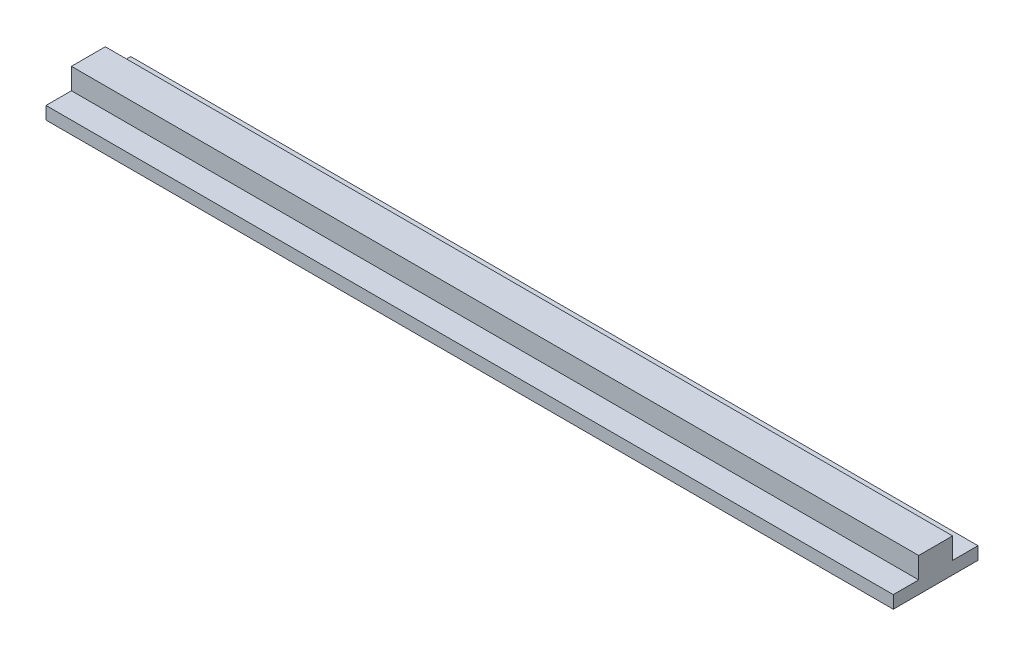
from build123d import *

# Parameters (mm, degrees)
RESSALTO_EXTRUS_O1_DEPTH = 1000
ESBO_O2_R                = 20
RESSALTO_EXTRUS_O2_DEPTH = 30


with BuildPart() as part:
    # Esboço1 → Ressalto-extrusão1 (new body, symmetric)
    with BuildSketch(Plane(origin=(0, 0, 0), x_dir=(0, 0, -1), z_dir=(1, 0, 0))):
        Polygon((-40, 80), (40, 80), (40, 30), (100, 30), (100, 0), (-100, 0), (-100, 30), (-40, 30), align=None)
    extrude(amount=RESSALTO_EXTRUS_O1_DEPTH, both=True)

    # Esboço2 → Ressalto-extrusão2 (add)
    with BuildSketch(Plane(origin=(0, 0, 0), x_dir=(-1, 0, 0), z_dir=(0, -1, 0))):
        Circle(ESBO_O2_R)
    extrude(amount=RESSALTO_EXTRUS_O2_DEPTH)


solid = part.part
